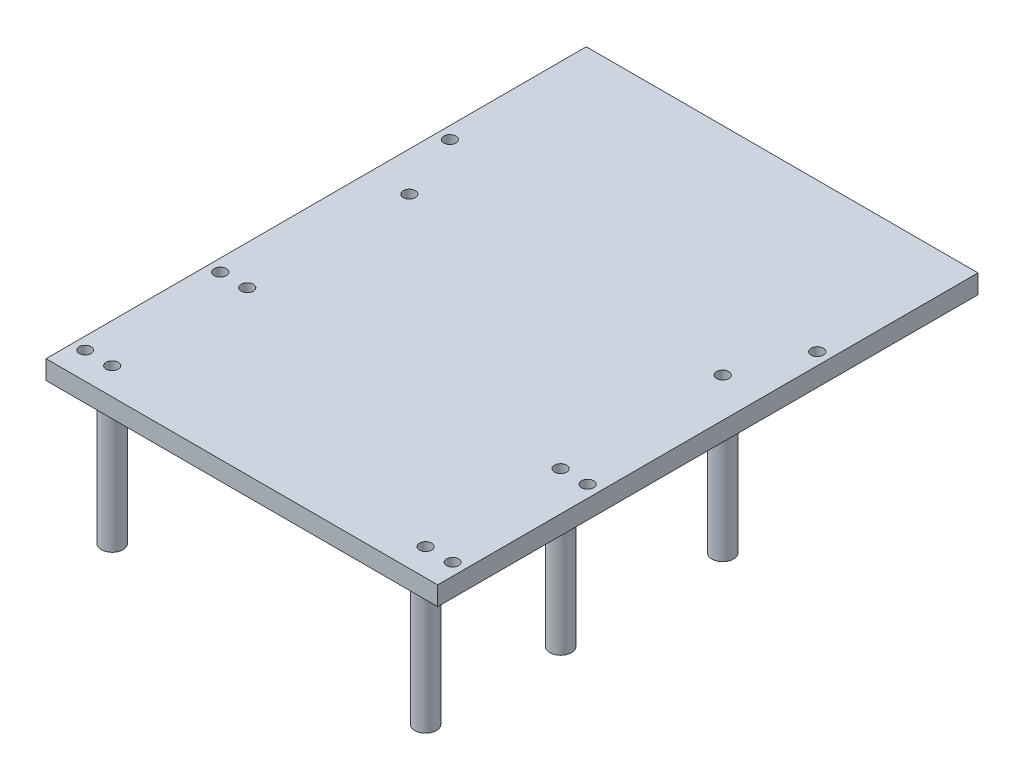
from build123d import *

# Parameters (mm, degrees)
SKETCH2_W           = 145
SKETCH2_H           = 200
BOSS_EXTRUDE1_DEPTH = 7
SKETCH5_R           = 2.25
SKETCH5_R_2         = 2.2
CUT_EXTRUDE1_DEPTH  = 33
SKETCH6_R           = 4
BOSS_EXTRUDE3_DEPTH = 50
SKETCH7_R           = 2.25
CUT_EXTRUDE2_DEPTH  = 58


with BuildPart() as part:
    # Sketch2 → Boss-Extrude1 (new body)
    with BuildSketch(Plane(origin=(0, 0, 0), x_dir=(1, 0, 0), z_dir=(0, 1, 0))):
        Rectangle(SKETCH2_W, SKETCH2_H)
    extrude(amount=BOSS_EXTRUDE1_DEPTH)

    # Sketch5 → Cut-Extrude1 (cut, through all)
    with BuildSketch(Plane(origin=(0, 32, 0), x_dir=(1, 0, 0), z_dir=(0, 1, 0))):
        with Locations((-68, 45)):
            Circle(SKETCH5_R)
        with Locations((-68, -40)):
            Circle(SKETCH5_R)
        with Locations((-68, -90)):
            Circle(SKETCH5_R_2)
        with Locations((68, -90)):
            Circle(SKETCH5_R_2)
        with Locations((68, -40)):
            Circle(SKETCH5_R)
        with Locations((68, 45)):
            Circle(SKETCH5_R)
    extrude(amount=-CUT_EXTRUDE1_DEPTH, mode=Mode.SUBTRACT)

    # Sketch6 → Boss-Extrude3 (add)
    with BuildSketch(Plane.XZ):
        with BuildLine():
            ThreePointArc((-58, 44), (-62, 40), (-58, 36))
            Line((-58, 36), (-58, 44))
        make_face()
        with BuildLine():
            Line((-58, 44), (-58, 36))
            ThreePointArc((-58, 36), (-55.171572875, 37.171572875), (-54, 40))
            ThreePointArc((-54, 40), (-55.171572875, 42.828427125), (-58, 44))
        make_face()
        with BuildLine():
            ThreePointArc((-54, 90), (-60.828427125, 92.828427125), (-58, 86))
            Line((-58, 86), (-58, 90))
            Line((-58, 90), (-54, 90))
        make_face()
        with BuildLine():
            Line((-58, 90), (-58, 86))
            ThreePointArc((-58, 86), (-55.171572875, 87.171572875), (-54, 90))
            Line((-54, 90), (-58, 90))
        make_face()
        with Locations((58, 90)):
            Circle(SKETCH6_R)
        with Locations((-58, -20)):
            Circle(SKETCH6_R)
        with Locations((58, -20)):
            Circle(SKETCH6_R)
        with Locations((58, 40)):
            Circle(SKETCH6_R)
    extrude(amount=BOSS_EXTRUDE3_DEPTH)

    # Sketch7 → Cut-Extrude2 (cut, through all)
    with BuildSketch(Plane.XZ.offset(50)):
        with Locations((-58, 90)):
            Circle(SKETCH7_R)
        with Locations((-58, 40)):
            Circle(SKETCH7_R)
        with Locations((-58, -20)):
            Circle(SKETCH7_R)
        with Locations((58, -20)):
            Circle(SKETCH7_R)
        with Locations((58, 40)):
            Circle(SKETCH7_R)
        with Locations((58, 90)):
            Circle(SKETCH7_R)
    extrude(amount=-CUT_EXTRUDE2_DEPTH, mode=Mode.SUBTRACT)


solid = part.part
